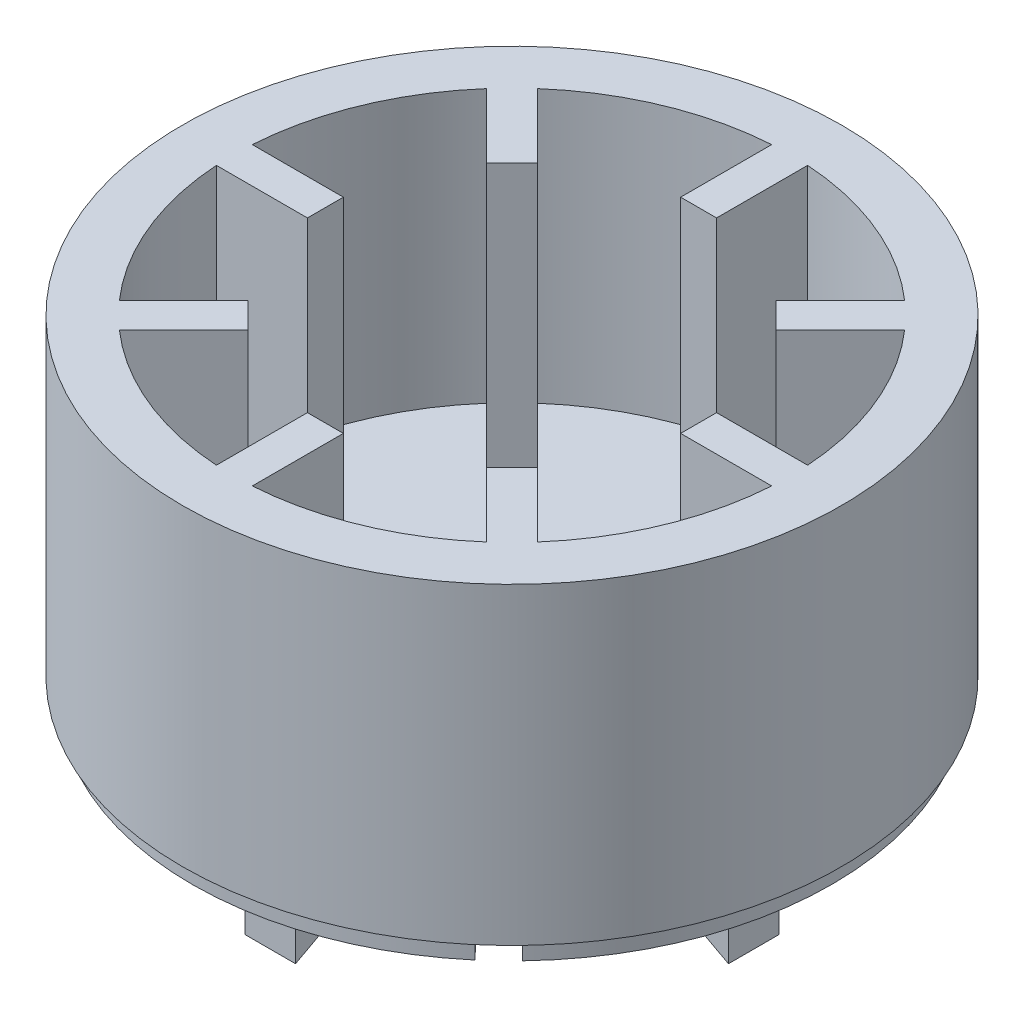
from build123d import *

# Parameters (mm, degrees)
SKETCH1_R           = 8.345
SKETCH1_R_2         = 7.045
BOSS_EXTRUDE1_DEPTH = 7.92
SKETCH2_R           = 7.045000007
BOSS_EXTRUDE2_DEPTH = 1.02
BOSS_EXTRUDE3_REACH = 16.213
BOSS_EXTRUDE4_DEPTH = 0.51
SKETCH5_W           = 1.28
SKETCH5_H           = 2.28
SKETCH5_W_2         = 2.28
SKETCH5_H_2         = 1.28
BOSS_EXTRUDE5_DEPTH = 2.41
CUT_EXTRUDE1_DEPTH  = 15.597796067
CUT_EXTRUDE2_DEPTH  = 2.41
CUT_EXTRUDE3_DEPTH  = 2.41


with BuildPart() as part:
    # Sketch1 → Boss-Extrude1 (new body)
    with BuildSketch(Plane(origin=(0, 0, 0), x_dir=(1, 0, 0), z_dir=(0, 1, 0))):
        Circle(SKETCH1_R)
        Circle(SKETCH1_R_2, mode=Mode.SUBTRACT)
    extrude(amount=BOSS_EXTRUDE1_DEPTH)

    # Sketch2 → Boss-Extrude2 (add)
    with BuildSketch(Plane(origin=(0, 0, 0), x_dir=(1, 0, 0), z_dir=(0, 1, 0))):
        Circle(SKETCH2_R)
    extrude(amount=BOSS_EXTRUDE2_DEPTH)

    # Sketch3 → Boss-Extrude3 (add, up to next)
    with BuildSketch(Plane(origin=(0, 7.92, 0), x_dir=(1, 0, 0), z_dir=(0, 1, 0)), mode=Mode.PRIVATE) as boss_extrude3_sk1:
        with BuildLine():
            Line((-0.455000106, 4.724999874), (0.455000106, 4.724999874))
            Line((0.455000106, 4.724999874), (0.455000106, 8.332586627))
            ThreePointArc((0.455000106, 8.332586627), (0, 8.345), (-0.455000106, 8.332586627))
            Line((-0.455000106, 8.332586627), (-0.455000106, 4.724999874))
        make_face()
    boss_extrude3_tool1 = extrude(boss_extrude3_sk1.sketch, amount=-BOSS_EXTRUDE3_REACH, mode=Mode.PRIVATE) - part.part
    # Sketch3 → Boss-Extrude3 (add, up to next)
    with BuildSketch(Plane(origin=(0, 7.92, 0), x_dir=(1, 0, 0), z_dir=(0, 1, 0)), mode=Mode.PRIVATE) as boss_extrude3_sk2:
        with BuildLine():
            Line((3.019345792, 3.662813112), (5.570294849, 6.213762169))
            ThreePointArc((5.570294849, 6.213762169), (5.900806089, 5.900806089), (6.213762169, 5.570294849))
            Line((6.213762169, 5.570294849), (3.662813112, 3.019345792))
            Line((3.662813112, 3.019345792), (3.019345792, 3.662813112))
        make_face()
    boss_extrude3_tool2 = extrude(boss_extrude3_sk2.sketch, amount=-BOSS_EXTRUDE3_REACH, mode=Mode.PRIVATE) - part.part
    # Sketch3 → Boss-Extrude3 (add, up to next)
    with BuildSketch(Plane(origin=(0, 7.92, 0), x_dir=(1, 0, 0), z_dir=(0, 1, 0)), mode=Mode.PRIVATE) as boss_extrude3_sk3:
        with BuildLine():
            Line((4.724999874, 0.455000106), (8.332586627, 0.455000106))
            ThreePointArc((8.332586627, 0.455000106), (8.345, 0), (8.332586627, -0.455000106))
            Line((8.332586627, -0.455000106), (4.724999874, -0.455000106))
            Line((4.724999874, -0.455000106), (4.724999874, 0.455000106))
        make_face()
    boss_extrude3_tool3 = extrude(boss_extrude3_sk3.sketch, amount=-BOSS_EXTRUDE3_REACH, mode=Mode.PRIVATE) - part.part
    # Sketch3 → Boss-Extrude3 (add, up to next)
    with BuildSketch(Plane(origin=(0, 7.92, 0), x_dir=(1, 0, 0), z_dir=(0, 1, 0)), mode=Mode.PRIVATE) as boss_extrude3_sk4:
        with BuildLine():
            Line((3.662813112, -3.019345792), (6.213762169, -5.570294849))
            ThreePointArc((6.213762169, -5.570294849), (5.900806089, -5.900806089), (5.570294849, -6.213762169))
            Line((5.570294849, -6.213762169), (3.019345792, -3.662813112))
            Line((3.019345792, -3.662813112), (3.662813112, -3.019345792))
        make_face()
    boss_extrude3_tool4 = extrude(boss_extrude3_sk4.sketch, amount=-BOSS_EXTRUDE3_REACH, mode=Mode.PRIVATE) - part.part
    # Sketch3 → Boss-Extrude3 (add, up to next)
    with BuildSketch(Plane(origin=(0, 7.92, 0), x_dir=(1, 0, 0), z_dir=(0, 1, 0)), mode=Mode.PRIVATE) as boss_extrude3_sk5:
        with BuildLine():
            Line((0.455000106, -4.724999874), (0.455000106, -8.332586627))
            ThreePointArc((0.455000106, -8.332586627), (0, -8.345), (-0.455000106, -8.332586627))
            Line((-0.455000106, -8.332586627), (-0.455000106, -4.724999874))
            Line((-0.455000106, -4.724999874), (0.455000106, -4.724999874))
        make_face()
    boss_extrude3_tool5 = extrude(boss_extrude3_sk5.sketch, amount=-BOSS_EXTRUDE3_REACH, mode=Mode.PRIVATE) - part.part
    # Sketch3 → Boss-Extrude3 (add, up to next)
    with BuildSketch(Plane(origin=(0, 7.92, 0), x_dir=(1, 0, 0), z_dir=(0, 1, 0)), mode=Mode.PRIVATE) as boss_extrude3_sk6:
        with BuildLine():
            Line((-3.019345792, -3.662813112), (-5.570294849, -6.213762169))
            ThreePointArc((-5.570294849, -6.213762169), (-5.900806089, -5.900806089), (-6.213762169, -5.570294849))
            Line((-6.213762169, -5.570294849), (-3.662813112, -3.019345792))
            Line((-3.662813112, -3.019345792), (-3.019345792, -3.662813112))
        make_face()
    boss_extrude3_tool6 = extrude(boss_extrude3_sk6.sketch, amount=-BOSS_EXTRUDE3_REACH, mode=Mode.PRIVATE) - part.part
    # Sketch3 → Boss-Extrude3 (add, up to next)
    with BuildSketch(Plane(origin=(0, 7.92, 0), x_dir=(1, 0, 0), z_dir=(0, 1, 0)), mode=Mode.PRIVATE) as boss_extrude3_sk7:
        with BuildLine():
            Line((-4.724999874, -0.455000106), (-8.332586627, -0.455000106))
            ThreePointArc((-8.332586627, -0.455000106), (-8.345, 0), (-8.332586627, 0.455000106))
            Line((-8.332586627, 0.455000106), (-4.724999874, 0.455000106))
            Line((-4.724999874, 0.455000106), (-4.724999874, -0.455000106))
        make_face()
    boss_extrude3_tool7 = extrude(boss_extrude3_sk7.sketch, amount=-BOSS_EXTRUDE3_REACH, mode=Mode.PRIVATE) - part.part
    # Sketch3 → Boss-Extrude3 (add, up to next)
    with BuildSketch(Plane(origin=(0, 7.92, 0), x_dir=(1, 0, 0), z_dir=(0, 1, 0)), mode=Mode.PRIVATE) as boss_extrude3_sk8:
        with BuildLine():
            Line((-3.662813112, 3.019345792), (-6.213762169, 5.570294849))
            ThreePointArc((-6.213762169, 5.570294849), (-5.900806089, 5.900806089), (-5.570294849, 6.213762169))
            Line((-5.570294849, 6.213762169), (-3.019345792, 3.662813112))
            Line((-3.019345792, 3.662813112), (-3.662813112, 3.019345792))
        make_face()
    boss_extrude3_tool8 = extrude(boss_extrude3_sk8.sketch, amount=-BOSS_EXTRUDE3_REACH, mode=Mode.PRIVATE) - part.part
    add(boss_extrude3_tool1.solids().sort_by_distance((0, 7.92, -6.532934))[0])
    add(boss_extrude3_tool2.solids().sort_by_distance((4.619482, 7.92, -4.619482))[0])
    add(boss_extrude3_tool3.solids().sort_by_distance((6.532934, 7.92, 0))[0])
    add(boss_extrude3_tool4.solids().sort_by_distance((4.619482, 7.92, 4.619482))[0])
    add(boss_extrude3_tool5.solids().sort_by_distance((0, 7.92, 6.532934))[0])
    add(boss_extrude3_tool6.solids().sort_by_distance((-4.619482, 7.92, 4.619482))[0])
    add(boss_extrude3_tool7.solids().sort_by_distance((-6.532934, 7.92, 0))[0])
    add(boss_extrude3_tool8.solids().sort_by_distance((-4.619482, 7.92, -4.619482))[0])

    # Sketch4 → Boss-Extrude4 (add)
    with BuildSketch(Plane.XZ):
        with BuildLine():
            ThreePointArc((6.179087875, -5.238791894), (8.097423758, 0.240407921), (5.857404636, 5.596148534))
            Line((5.857404636, 5.596148534), (2.927325729, 2.486761301))
            ThreePointArc((2.927325729, 2.486761301), (3.839300032, 0.113986642), (3.069700642, -2.308712987))
            Line((3.069700642, -2.308712987), (6.179087875, -5.238791894))
        make_face()
        with BuildLine():
            Line((2.308712987, 3.069700642), (5.238791894, 6.179087875))
            ThreePointArc((5.238791894, 6.179087875), (-0.240407921, 8.097423758), (-5.596148534, 5.857404636))
            Line((-5.596148534, 5.857404636), (-2.486761301, 2.927325729))
            ThreePointArc((-2.486761301, 2.927325729), (-0.113986642, 3.839300032), (2.308712987, 3.069700642))
        make_face()
        with BuildLine():
            Line((-3.069700642, 2.308712987), (-6.179087875, 5.238791894))
            ThreePointArc((-6.179087875, 5.238791894), (-8.097423758, -0.240407921), (-5.857404636, -5.596148534))
            Line((-5.857404636, -5.596148534), (-2.927325729, -2.486761301))
            ThreePointArc((-2.927325729, -2.486761301), (-3.839300032, -0.113986642), (-3.069700642, 2.308712987))
        make_face()
        with BuildLine():
            ThreePointArc((-5.238791894, -6.179087875), (0.240407921, -8.097423758), (5.596148534, -5.857404636))
            Line((5.596148534, -5.857404636), (2.486761301, -2.927325729))
            ThreePointArc((2.486761301, -2.927325729), (0.113986642, -3.839300032), (-2.308712987, -3.069700642))
            Line((-2.308712987, -3.069700642), (-5.238791894, -6.179087875))
        make_face()
    extrude(amount=BOSS_EXTRUDE4_DEPTH)

    # Sketch5 → Boss-Extrude5 (add)
    with BuildSketch(Plane.XZ.offset(0.51)):
        with Locations((0, 4.98099181)):
            Rectangle(SKETCH5_W, SKETCH5_H)
        with Locations((4.98099181, 0)):
            Rectangle(SKETCH5_W_2, SKETCH5_H_2)
        with Locations((0, -4.98099181)):
            Rectangle(SKETCH5_W, SKETCH5_H)
        with Locations((-4.98099181, 0)):
            Rectangle(SKETCH5_W_2, SKETCH5_H_2)
    extrude(amount=BOSS_EXTRUDE5_DEPTH)

    # Sketch6 → Cut-Extrude1 (cut, through all)
    with BuildSketch(Plane(origin=(0, 0, -0.64), x_dir=(-1, 0, 0), z_dir=(0, 0, -1))):
        Polygon((6.12099181, -2.92), (3.84099181, -1.7), (3.84099181, -2.92), align=None)
    extrude(amount=-CUT_EXTRUDE1_DEPTH, mode=Mode.SUBTRACT)

    # Sketch7 → Cut-Extrude2 (cut)
    with BuildSketch(Plane(origin=(0.64, 0, 0), x_dir=(0, 0, -1), z_dir=(1, 0, 0))):
        Polygon((6.12099181, -2.92), (3.84099181, -1.7), (3.84099181, -2.92), align=None)
        Polygon((-3.84099181, -2.92), (-3.84099181, -1.7), (-6.12099181, -2.92), align=None)
    extrude(amount=-CUT_EXTRUDE2_DEPTH, mode=Mode.SUBTRACT)

    # Sketch6_3 → Cut-Extrude3 (cut)
    with BuildSketch(Plane(origin=(0, 0, -0.64), x_dir=(-1, 0, 0), z_dir=(0, 0, -1))):
        Polygon((-3.84099181, -2.92), (-3.84099181, -1.7), (-6.12099181, -2.92), align=None)
    extrude(amount=-CUT_EXTRUDE3_DEPTH, mode=Mode.SUBTRACT)


solid = part.part
